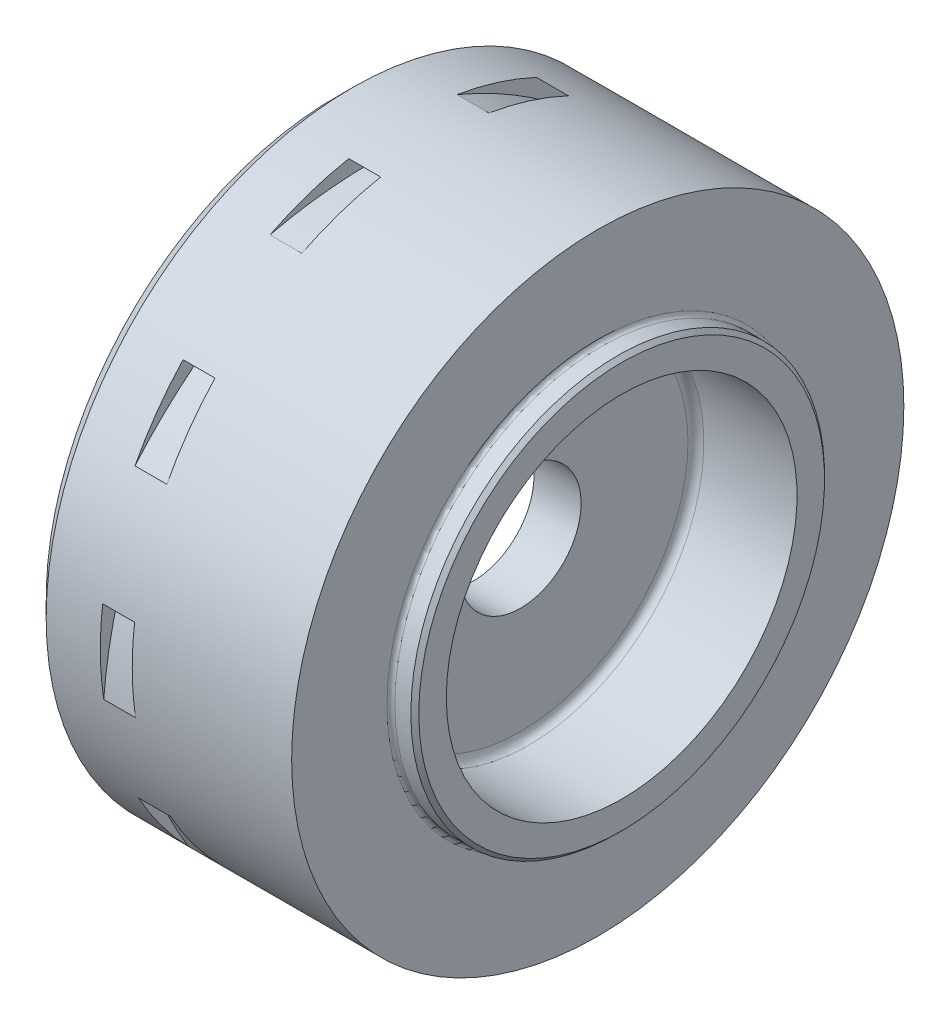
from build123d import *
from build123d.topology import SkipClean

# Parameters (mm, degrees)
AUFSATZ_LINEAR_AUSTRAGEN1_DEPTH = 2
KREISMUSTER1_COUNT              = 10
VERRUNDUNG1_R                   = 0.5
VERRUNDUNG2_R                   = 0.25
VERRUNDUNG3_R                   = 0.5
VERRUNDUNG4_R                   = 0.5
VERRUNDUNG15_R                  = 0.1
CHAMFER1_SIZE                   = 1


with BuildPart() as part:
    # Skizze1 → Rotation1 (revolve)
    with BuildSketch(Plane.XY, mode=Mode.PRIVATE) as rotation1_sk:
        Polygon((1.521652912, 19.2), (9.321652912, 19.2), (9.321652912, 12.975), (10.571652912, 12.975), (10.821652912, 12.725), (10.821652912, 11), (4.478528889, 11), (4.478528889, 3.8), (1.521652912, 3.8), (1.521652912, 15.65), (-0.678347088, 17.85), (-0.678347088, 19.2), align=None)
        Polygon((-2.678347088, 19.2), (-2.678347088, 17.85), (-4.678347088, 15.83), (-7.078347088, 15.83), (-7.078347088, 19.2), align=None)
    revolve(rotation1_sk.sketch.rotate(Axis((-34.5671687, 0, 0), (1, 0, 0)), 90), axis=Axis((-34.5671687, 0, 0), (1, 0, 0)))

    # Skizze4 → Aufsatz-Linear austragen1 (add)
    with SkipClean():  # the faces are left unmerged after this step: merging them gives an invalid solid
        with BuildSketch(Plane(origin=(-2.678347088, 0, 0), x_dir=(0, 0, -1), z_dir=(1, 0, 0))):
            with BuildLine():
                ThreePointArc((-4.9, 17.164279769), (-2.473874099, 17.677738739), (0, 17.85))
                ThreePointArc((0, 17.85), (-4.307636602, 17.848321342), (-8.563792331, 17.184337663))
                ThreePointArc((-8.563792331, 17.184337663), (-11.467535036, 15.399209077), (-14.009856096, 13.128744501))
                add(Edge.make_bspline(
                    [(-14.009856096, 13.128744501), (-13.341857151, 13.573563795), (-12.627018081, 13.888836451), (-10.152830084, 15.518440927)],
                    knots=[0, 0, 0, 0, 1, 1, 1, 1], degree=3))
                add(Edge.make_bspline(
                    [(-10.152830084, 15.518440927), (-7.674292693, 17.156563061), (-6.075813649, 16.924356638), (-4.9, 17.164279769)],
                    knots=[0.132495074, 0.132495074, 0.132495074, 0.132495074, 1.132495074, 1.132495074, 1.132495074, 1.132495074], degree=3))
            make_face()
        aufsatz_linear_austragen1 = extrude(amount=AUFSATZ_LINEAR_AUSTRAGEN1_DEPTH)

    # Kreismuster1: Aufsatz-Linear austragen1 ×10 about axis
    with SkipClean():  # the faces are left unmerged after this step: merging them gives an invalid solid
        kreismuster1_axis = Axis((-34.5671687, 0, 0), (-1, 0, 0))
        for i in range(1, KREISMUSTER1_COUNT):
            add(aufsatz_linear_austragen1.rotate(kreismuster1_axis, i * 360 / KREISMUSTER1_COUNT))

    # Verrundung1
    verrundung1_edges = [part.edges().sort_by_distance(p)[0] for p in [
        (4.478528889, 0, -11),
    ]]
    fillet(verrundung1_edges, radius=VERRUNDUNG1_R)

    # Verrundung2
    verrundung2_edges = [part.edges().sort_by_distance(p)[0] for p in [
        (9.321652912, 0, -12.975),
    ]]
    fillet(verrundung2_edges, radius=VERRUNDUNG2_R)

    # Verrundung3
    verrundung3_edges = [part.edges().sort_by_distance(p)[0] for p in [
        (1.521652912, 0, -15.65),
    ]]
    fillet(verrundung3_edges, radius=VERRUNDUNG3_R)

    # Verrundung4
    verrundung4_edges = [part.edges().sort_by_distance(p)[0] for p in [
        (-4.678347088, 0, -15.83),
    ]]
    fillet(verrundung4_edges, radius=VERRUNDUNG4_R)

    # Verrundung15
    verrundung15_edges = [part.edges().sort_by_distance(p)[0] for p in [
        (-1.678347088, -14.44095335, 10.491966753),
        (-1.678347088, -17.85, 0),
        (-1.678347088, -14.44095335, -10.491966753),
        (-1.678347088, -5.51595335, -16.976358816),
        (-1.678347088, 5.51595335, -16.976358816),
        (-1.678347088, 14.44095335, -10.491966753),
        (-1.678347088, 17.85, 0),
        (-1.678347088, 14.44095335, 10.491966753),
        (-1.678347088, 5.51595335, 16.976358816),
        (-1.678347088, -5.51595335, 16.976358816),
    ]]
    fillet(verrundung15_edges, radius=VERRUNDUNG15_R)

    # Chamfer1
    chamfer1_edges = [part.edges().sort_by_distance(p)[0] for p in [
        (-7.078347088, 0, -15.83),
        (-7.078347088, 0, -19.2),
    ]]
    chamfer(chamfer1_edges, length=CHAMFER1_SIZE)


solid = part.part
